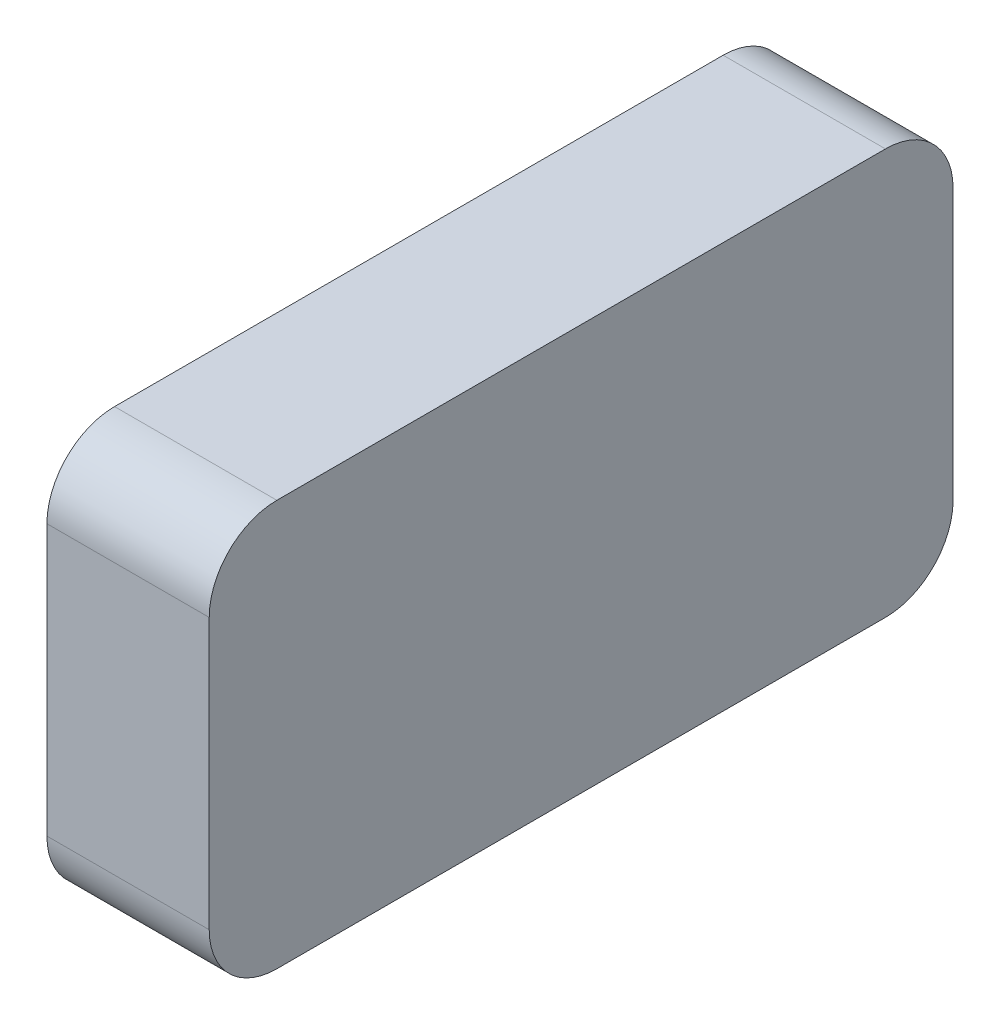
from build123d import *

# Parameters (mm, degrees)
EXTRUDE_1_DEPTH     = 12
SKETCH_2_R          = 8
CUT_EXTRUDE_1_DEPTH = 8
SKETCH_3_R          = 2.5
CUT_EXTRUDE_2_DEPTH = 10


with BuildPart() as part:
    # 草图1 → 凸台-拉伸1 (new body)
    with BuildSketch(Plane(origin=(0, 0, 0), x_dir=(0, 0, -1), z_dir=(1, 0, 0))):
        with BuildLine():
            Line((-22.5, 15), (22.5, 15))
            ThreePointArc((22.5, 15), (26.035533906, 13.535533906), (27.5, 10))
            Line((27.5, 10), (27.5, -10))
            ThreePointArc((27.5, -10), (26.035533906, -13.535533906), (22.5, -15))
            Line((22.5, -15), (-22.5, -15))
            ThreePointArc((-22.5, -15), (-26.035533906, -13.535533906), (-27.5, -10))
            Line((-27.5, -10), (-27.5, 10))
            ThreePointArc((-27.5, 10), (-26.035533906, 13.535533906), (-22.5, 15))
        make_face()
    extrude(amount=EXTRUDE_1_DEPTH)

    # 草图2 → 切除-拉伸1 (cut)
    with BuildSketch(Plane.ZY):
        Circle(SKETCH_2_R)
    extrude(amount=-CUT_EXTRUDE_1_DEPTH, mode=Mode.SUBTRACT)

    # 草图3 → 切除-拉伸2 (cut)
    with BuildSketch(Plane.XZ.offset(15)):
        with Locations((3, 0)):
            Circle(SKETCH_3_R)
    extrude(amount=-CUT_EXTRUDE_2_DEPTH, mode=Mode.SUBTRACT)


solid = part.part
